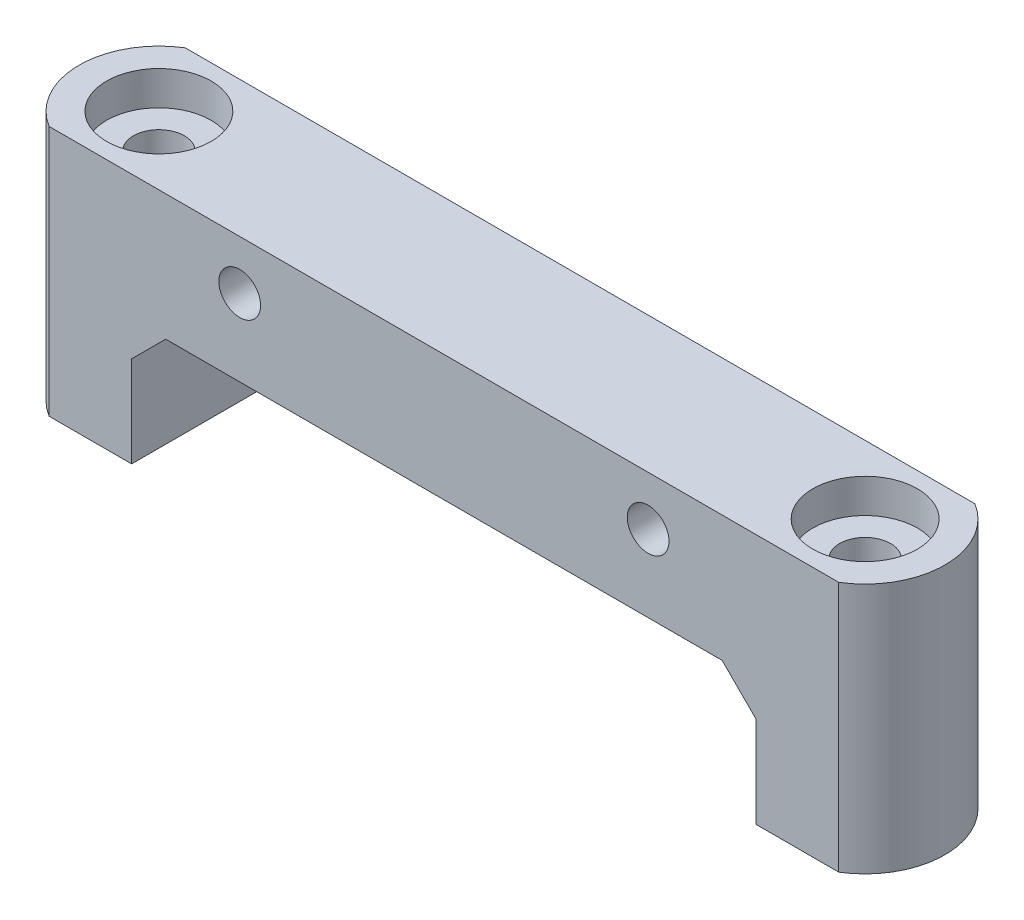
from build123d import *

# Parameters (mm, degrees)
SKETCH1_R               = 1
BOSS_EXTRUDE1_DEPTH     = 8
SKETCH2_R               = 1.5
CUT_EXTRUDE1_DEPTH      = 15.75
BOSS_EXTRUDE2_DEPTH     = 14.75
SKETCH5_R               = 3.075
CUT_EXTRUDE2_DEPTH      = 1
CUT_EXTRUDE2_DEPTH_BACK = 2
CHAMFER2_SIZE           = 2
SKETCH6_R               = 1.225
CUT_EXTRUDE3_DEPTH      = 5


with BuildPart() as part:
    # Sketch1 → Boss-Extrude1 (new body)
    with BuildSketch(Plane.XY):
        Polygon((18.35, 7.35), (18.35, 0), (23.2, 0), (23.2, 14.75), (-23.2, 14.75), (-23.2, 0), (-18.35, 0), (-18.35, 7.35), align=None)
        with Locations((-12, 11.85)):
            Circle(SKETCH1_R, mode=Mode.SUBTRACT)
        with Locations((12, 11.85)):
            Circle(SKETCH1_R, mode=Mode.SUBTRACT)
    extrude(amount=BOSS_EXTRUDE1_DEPTH)

    # Sketch2 → Cut-Extrude1 (cut, through all)
    with BuildSketch(Plane.XZ):
        with Locations((-20.75, 4)):
            Circle(SKETCH2_R)
        with Locations((20.75, 4)):
            Circle(SKETCH2_R)
    extrude(amount=-CUT_EXTRUDE1_DEPTH, mode=Mode.SUBTRACT)

    # Sketch3 → Boss-Extrude2 (add)
    with BuildSketch(Plane(origin=(0, 14.75, 0), x_dir=(1, 0, 0), z_dir=(0, 1, 0))):
        with BuildLine():
            Line((23.2, -8), (23.2, 0))
            ThreePointArc((23.2, 0), (25.440682253, -4), (23.2, -8))
        make_face()
        with BuildLine():
            Line((-23.2, -8), (-23.2, 0))
            ThreePointArc((-23.2, 0), (-25.440682253, -4), (-23.2, -8))
        make_face()
    extrude(amount=-BOSS_EXTRUDE2_DEPTH)

    # Sketch5 → Cut-Extrude2 (cut, two sides)
    with BuildSketch(Plane(origin=(0, 14.75, 0), x_dir=(1, 0, 0), z_dir=(0, 1, 0))) as cut_extrude2_sk:
        with Locations((20.75, -4)):
            Circle(SKETCH5_R)
        with Locations((-20.75, -4)):
            Circle(SKETCH5_R)
    extrude(amount=CUT_EXTRUDE2_DEPTH, mode=Mode.SUBTRACT)
    extrude(cut_extrude2_sk.sketch, amount=-CUT_EXTRUDE2_DEPTH_BACK, mode=Mode.SUBTRACT)

    # Chamfer2
    chamfer2_edges = [part.edges().sort_by_distance(p)[0] for p in [
        (-18.35, 7.35, 4),
        (18.35, 7.35, 4),
    ]]
    chamfer(chamfer2_edges, length=CHAMFER2_SIZE)

    # Sketch6 → Cut-Extrude3 (cut)
    with BuildSketch(Plane.XY.offset(8)):
        with Locations((-12, 11.85)):
            Circle(SKETCH6_R)
        with Locations((12, 11.85)):
            Circle(SKETCH6_R)
    extrude(amount=-CUT_EXTRUDE3_DEPTH, mode=Mode.SUBTRACT)


solid = part.part
